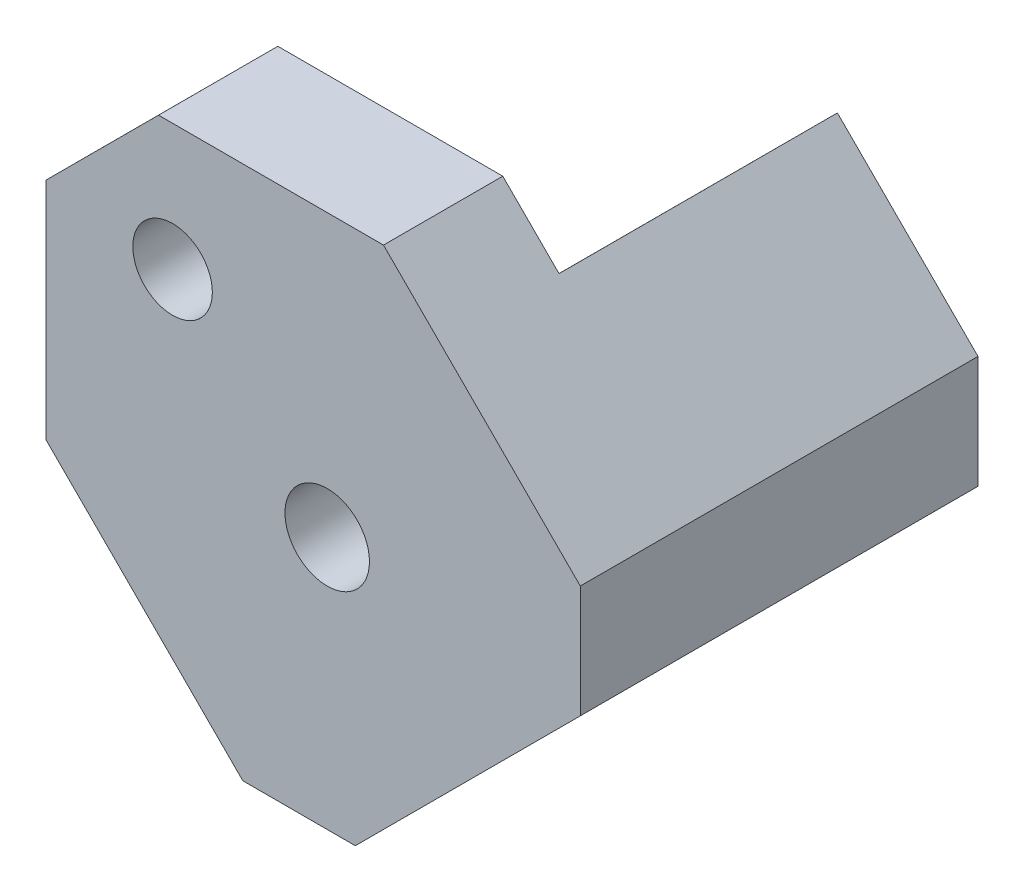
from build123d import *

# Parameters (mm, degrees)
BASE_EXTRUDE_DEPTH               = 63.5
F_1_2_20_TAPPED_HOLE1_D          = 12.7
F_17_32_0_53125_DIAMETER_HOLE2_D = 13.49375
SKETCH10_W                       = 44.45
SKETCH10_H                       = 38.1
CUT_EXTRUDE1_DEPTH               = 99.427952329
F_1_2_20_TAPPED_HOLE3_D          = 12.7


with BuildPart() as part:
    # Sketch1 → Base-Extrude (new body)
    with BuildSketch(Plane.XY):
        Polygon((128.574722886, -68.854481025), (128.572634607, -86.814993146), (92.647433807, -122.731840829), (74.686921686, -122.729752549), (43.259679964, -91.295201849), (43.263856522, -55.374177607), (61.226456923, -37.415753766), (97.147481164, -37.419930325), align=None)
    extrude(amount=BASE_EXTRUDE_DEPTH)

    # 1/2-20 Tapped Hole1 (through all)
    with Locations(Plane.XY.offset(63.5)):
        with Locations((63.469171623, -57.621590937)):
            Hole(F_1_2_20_TAPPED_HOLE1_D / 2)

    # 17/32 (0.53125) Diameter Hole2 (through all)
    with Locations(Plane.XY.offset(63.5)):
        with Locations((88.162004405, -82.320166487)):
            Hole(F_17_32_0_53125_DIAMETER_HOLE2_D / 2)

    # Sketch10 → Cut-Extrude1 (cut, through all)
    with BuildSketch(Plane(origin=(-24.01272988, -24.00714658, 0), x_dir=(0, 0, 1), z_dir=(-0.707188992, -0.707024561, 0))):
        with Locations((22.225, -88.798618004)):
            Rectangle(SKETCH10_W, SKETCH10_H)
    extrude(amount=-CUT_EXTRUDE1_DEPTH, mode=Mode.SUBTRACT)

    # 1/2-20 Tapped Hole3 (through all)
    with Locations(Plane(origin=(107.678863486, -107.703906169, 0), x_dir=(0.707188992, 0.707024561, 0), z_dir=(0.707024561, -0.707188992, 0))):
        with Locations((-14.905180506, 25.4)):
            Hole(F_1_2_20_TAPPED_HOLE3_D / 2)


solid = part.part
